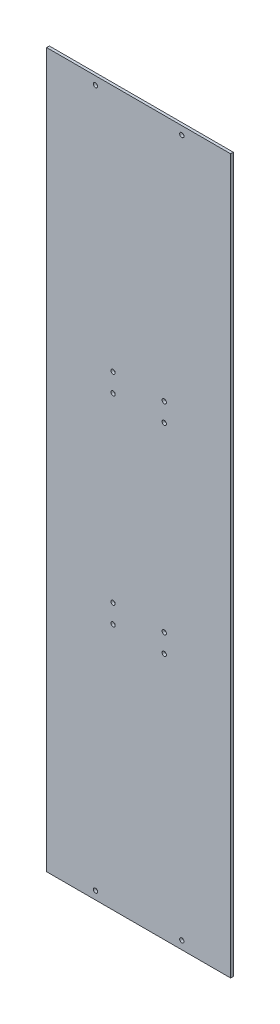
from build123d import *

# Parameters (mm, degrees)
SKETCH1_W           = 107.65282
SKETCH1_H           = 417.83
BOSS_EXTRUDE1_DEPTH = 1.5875
SKETCH2_R           = 1.26619
CUT_EXTRUDE1_DEPTH  = 1.5875
SKETCH4_R           = 1.26619
CUT_EXTRUDE2_DEPTH  = 2.5875


with BuildPart() as part:
    # Sketch1 → Boss-Extrude1 (new body)
    with BuildSketch(Plane.XY):
        Rectangle(SKETCH1_W, SKETCH1_H)
    extrude(amount=BOSS_EXTRUDE1_DEPTH)

    # Sketch2 → Cut-Extrude1 (cut)
    with BuildSketch(Plane(origin=(0, 0, 0), x_dir=(-1, 0, 0), z_dir=(0, 0, -1))):
        with Locations((25.284421279, -204.1525)):
            Circle(SKETCH2_R)
        with Locations((-25.284421279, -204.1525)):
            Circle(SKETCH2_R)
        with Locations((25.284421279, 204.1525)):
            Circle(SKETCH2_R)
        with Locations((-25.284421279, 204.1525)):
            Circle(SKETCH2_R)
    extrude(amount=-CUT_EXTRUDE1_DEPTH, mode=Mode.SUBTRACT)

    # Sketch4 → Cut-Extrude2 (cut, through all)
    with BuildSketch(Plane.XY.offset(1.5875)):
        with Locations((14.986, 53.086)):
            Circle(SKETCH4_R)
        with Locations((-14.986, 53.086)):
            Circle(SKETCH4_R)
        with Locations((14.986, -53.086)):
            Circle(SKETCH4_R)
        with Locations((-14.986, -53.086)):
            Circle(SKETCH4_R)
        with Locations((14.986, 64.008)):
            Circle(SKETCH4_R)
        with Locations((-14.986, 64.008)):
            Circle(SKETCH4_R)
        with Locations((14.986, -64.008)):
            Circle(SKETCH4_R)
        with Locations((-14.986, -64.008)):
            Circle(SKETCH4_R)
    extrude(amount=-CUT_EXTRUDE2_DEPTH, mode=Mode.SUBTRACT)


solid = part.part
